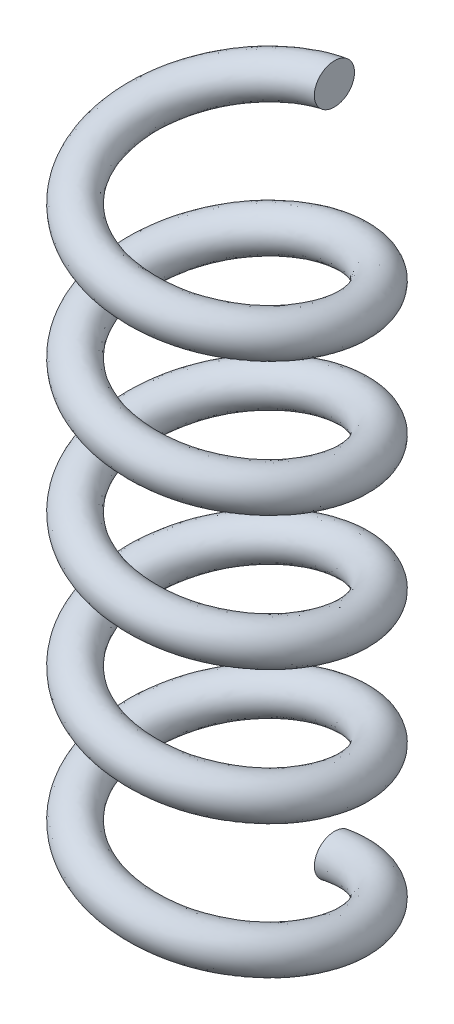
from build123d import *

# Parameters (mm, degrees)
SWEEP1_PITCH       = 2.531872
SWEEP1_HEIGHT      = 12.65936
SWEEP1_RADIUS      = 2.03835
SWEEP1_START_ANGLE = -180
SKETCH4_R          = 0.381


with BuildPart() as part:
    # Sweep1: sweep along a helix
    with BuildLine() as sweep1_path:
        add(Helix(SWEEP1_PITCH, SWEEP1_HEIGHT, SWEEP1_RADIUS, center=(0, 0, 0), direction=(0, 1, 0), lefthand=True, mode=Mode.PRIVATE).rotate(Axis((0, 0, 0), (0, 1, 0)), SWEEP1_START_ANGLE))
    # Sketch4 → Sweep1 (sweep)
    with BuildSketch(Plane(origin=(0, 0, 0), x_dir=(0, 0, -1), z_dir=(1, 0, 0))):
        with Locations((2.038355947, 12.659490975)):
            Circle(SKETCH4_R)
    sweep(path=sweep1_path.line, is_frenet=True)


solid = part.part
